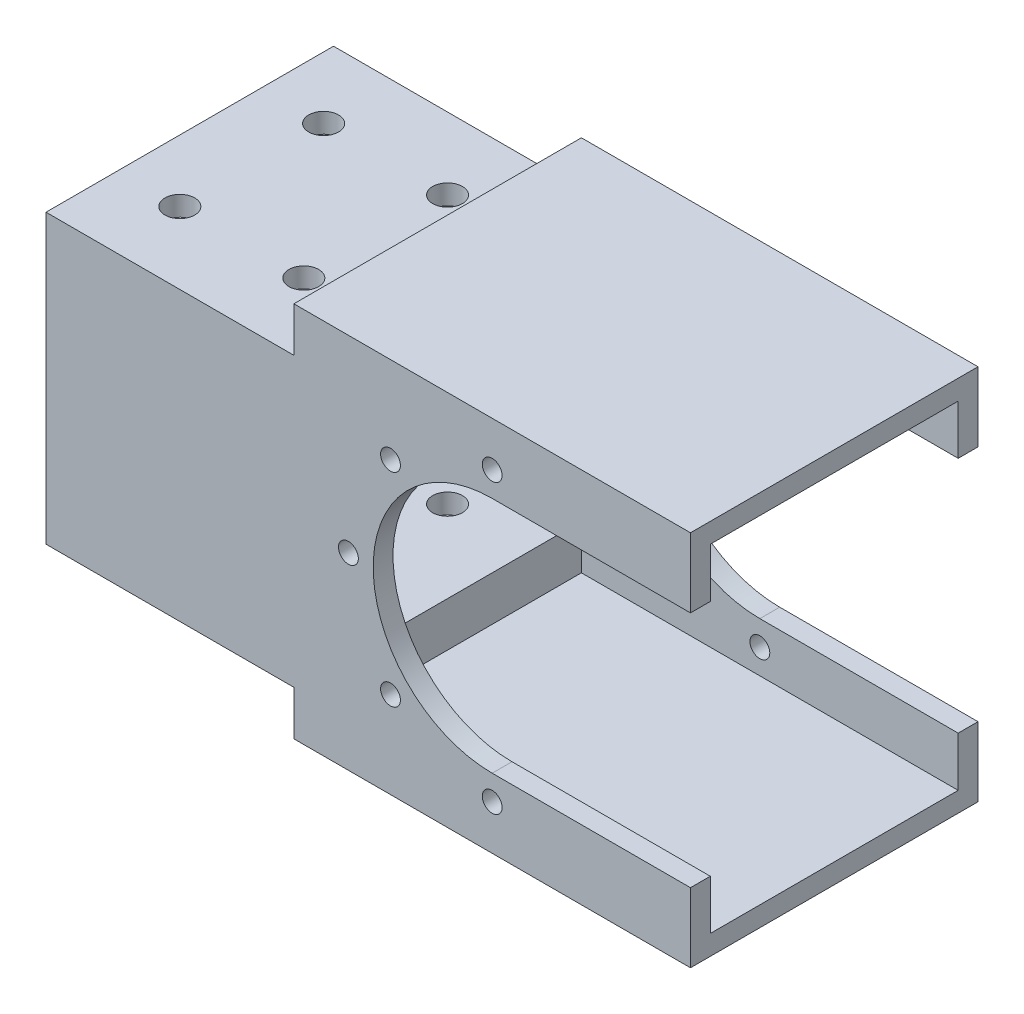
from build123d import *

# Parameters (mm, degrees)
BOSS_EXTRUDE1_DEPTH = 58
SHELL1_T            = -4
SKETCH2_R           = 2
CUT_EXTRUDE1_DEPTH  = 60
SKETCH3_R           = 3
CUT_EXTRUDE2_DEPTH  = 70


with BuildPart() as part:
    # Sketch1 → Boss-Extrude1 (new body)
    with BuildSketch(Plane.XY):
        Polygon((-25, -29), (25, -29), (25, -38), (105, -38), (105, 38), (25, 38), (25, 29), (-25, 29), align=None)
    extrude(amount=BOSS_EXTRUDE1_DEPTH)

    # Shell1
    shell1_openings = [part.faces().sort_by_distance(p)[0] for p in [
        (105, 0, 29),
        (-25, 0, 29),
    ]]
    offset(amount=SHELL1_T, openings=shell1_openings, kind=Kind.INTERSECTION)

    # Sketch2 → Cut-Extrude1 (cut)
    with BuildSketch(Plane(origin=(0, 0, 0), x_dir=(-1, 0, 0), z_dir=(0, 0, -1))):
        with Locations((-36, 0)):
            Circle(SKETCH2_R)
        with Locations((-44.493903346, -20.506096654)):
            Circle(SKETCH2_R)
        with Locations((-65, -29)):
            Circle(SKETCH2_R)
        with Locations((-65, 29)):
            Circle(SKETCH2_R)
        with Locations((-44.493903346, 20.506096654)):
            Circle(SKETCH2_R)
        with BuildLine():
            Line((-65, 24), (-105, 24))
            Line((-105, 24), (-105, -24))
            Line((-105, -24), (-65, -24))
            ThreePointArc((-65, -24), (-41, 0), (-65, 24))
        make_face()
    extrude(amount=-CUT_EXTRUDE1_DEPTH, mode=Mode.SUBTRACT)

    # Sketch3 → Cut-Extrude2 (cut)
    with BuildSketch(Plane.XZ.offset(29)):
        with Locations((12.5, 43.5)):
            Circle(SKETCH3_R)
        with Locations((-12.5, 43.5)):
            Circle(SKETCH3_R)
        with Locations((-12.5, 14.5)):
            Circle(SKETCH3_R)
        with Locations((12.5, 14.5)):
            Circle(SKETCH3_R)
    extrude(amount=-CUT_EXTRUDE2_DEPTH, mode=Mode.SUBTRACT)


solid = part.part
